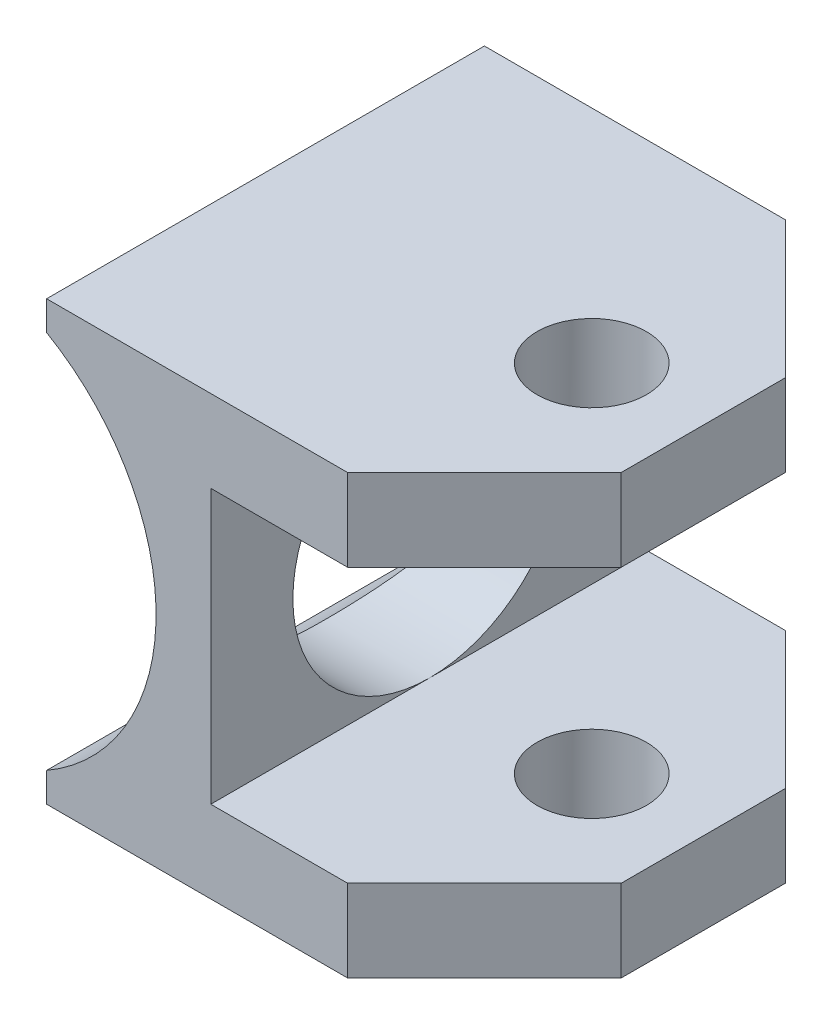
from build123d import *

# Parameters (mm, degrees)
BOSS_EXTRUDE1_DEPTH         = 25.4
F_1_4_0_25_DIAMETER_HOLE1_D = 6.35
CHAMFER1_SIZE               = 7.9375
SKETCH6_R                   = 7.9375
CUT_EXTRUDE1_DEPTH          = 10.525


with BuildPart() as part:
    # Sketch1 → Boss-Extrude1 (new body)
    with BuildSketch(Plane.XY):
        with BuildLine():
            Line((6.35, 12.7), (31.75, 12.7))
            Line((31.75, 12.7), (31.75, 7.9375))
            Line((31.75, 7.9375), (15.875, 7.9375))
            Line((15.875, 7.9375), (15.875, -7.9375))
            Line((15.875, -7.9375), (31.75, -7.9375))
            Line((31.75, -7.9375), (31.75, -12.7))
            Line((31.75, -12.7), (6.35, -12.7))
            Line((6.35, -12.7), (6.35, -10.998522628))
            ThreePointArc((6.35, -10.998522628), (12.7, 0), (6.35, 10.998522628))
            Line((6.35, 10.998522628), (6.35, 12.7))
        make_face()
    extrude(amount=BOSS_EXTRUDE1_DEPTH)

    # 1/4 (0.25) Diameter Hole1 (through all)
    with Locations(Plane(origin=(0, 12.7, 0), x_dir=(1, 0, 0), z_dir=(0, 1, 0))):
        with Locations((25.4, -12.821774192)):
            Hole(F_1_4_0_25_DIAMETER_HOLE1_D / 2)

    # Chamfer1
    chamfer1_edges = [part.edges().sort_by_distance(p)[0] for p in [
        (31.75, 10.31875, 0),
        (31.75, 10.31875, 25.4),
        (31.75, -10.31875, 25.4),
        (31.75, -10.31875, 0),
    ]]
    chamfer(chamfer1_edges, length=CHAMFER1_SIZE)

    # Sketch6 → Cut-Extrude1 (cut, through all)
    with BuildSketch(Plane(origin=(15.875, 0, 0), x_dir=(0, 0, -1), z_dir=(1, 0, 0))):
        with Locations((-12.7, 0)):
            Circle(SKETCH6_R)
    extrude(amount=-CUT_EXTRUDE1_DEPTH, mode=Mode.SUBTRACT)


solid = part.part
